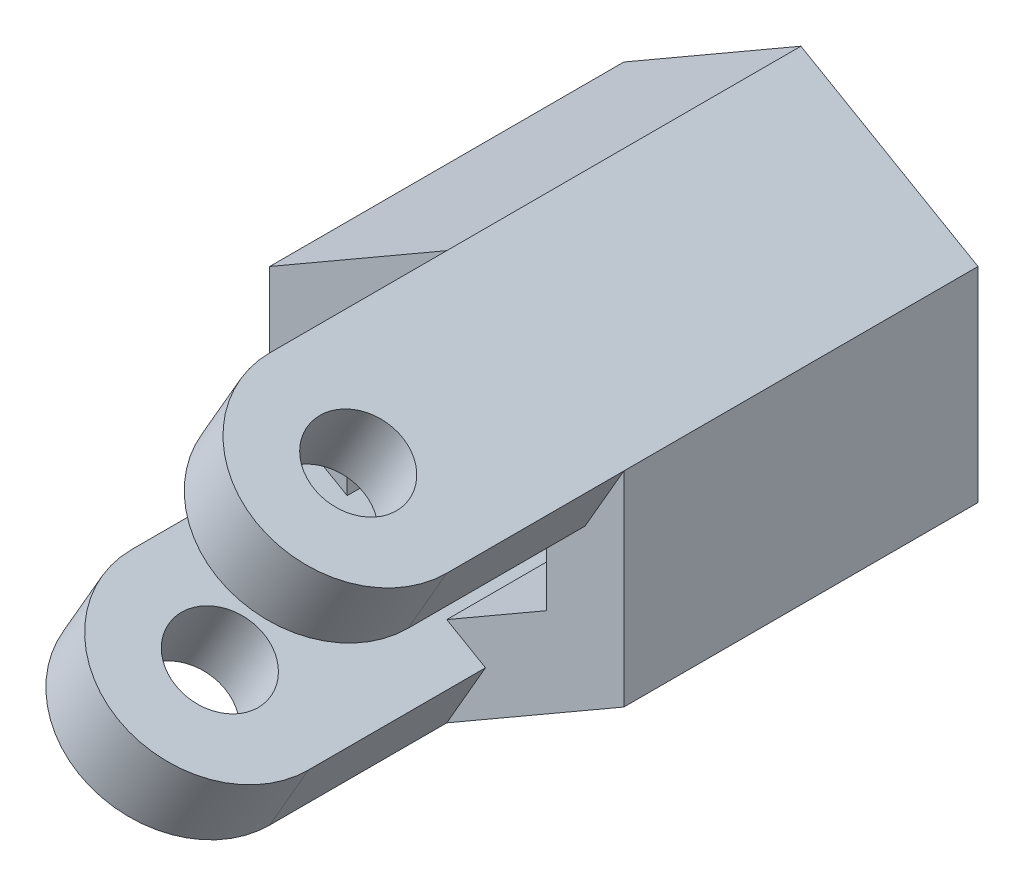
from build123d import *

# Parameters (mm, degrees)
EXTRUDE_1_DEPTH = 6
SKETCH_2_R      = 1.25
EXTRUDE_2_DEPTH = 2
SKETCH_3_R      = 1
EXTRUDE_4_DEPTH = 1.75
SKETCH_4_R      = 1
EXTRUDE_7_DEPTH = 1.75


with BuildPart() as part:
    # 스케치1 → 보스-돌출1 (new body)
    with BuildSketch(Plane.XY):
        Polygon((0, 4.618802154), (-4, 2.309401077), (-4, -2.309401077), (0, -4.618802154), (4, -2.309401077), (4, 2.309401077), align=None)
        Polygon((0, 2.598076211), (-2.25, 1.299038106), (-2.25, -1.299038106), (0, -2.598076211), (2.25, -1.299038106), (2.25, 1.299038106), align=None, mode=Mode.SUBTRACT)
    extrude(amount=EXTRUDE_1_DEPTH)

    # 스케치2 → 보스-돌출2 (add)
    with BuildSketch(Plane(origin=(0, 0, 0), x_dir=(-1, 0, 0), z_dir=(0, 0, -1))):
        Polygon((0, 4.618802154), (-4, 2.309401077), (-4, -2.309401077), (0, -4.618802154), (4, -2.309401077), (4, 2.309401077), align=None)
        Circle(SKETCH_2_R, mode=Mode.SUBTRACT)
    extrude(amount=EXTRUDE_2_DEPTH)

    # 스케치3 → 보스-돌출4 (add)
    with BuildSketch(Plane(origin=(2, 3.464101615, 0), x_dir=(0.866025404, -0.5, 0), z_dir=(0.5, 0.866025404, 0))):
        with BuildLine():
            Line((-2.309401077, -6), (2.309401077, -6))
            Line((2.309401077, -6), (2.309401077, -10))
            ThreePointArc((2.309401077, -10), (0, -12.309401077), (-2.309401077, -10))
            Line((-2.309401077, -10), (-2.309401077, -6))
        make_face()
        with Locations((0, -10)):
            Circle(SKETCH_3_R, mode=Mode.SUBTRACT)
    extrude(amount=-EXTRUDE_4_DEPTH)

    # 스케치4 → 보스-돌출7 (add)
    with BuildSketch(Plane(origin=(-2, -3.464101615, 0), x_dir=(0.866025404, -0.5, 0), z_dir=(-0.5, -0.866025404, 0))):
        with BuildLine():
            Line((-2.309401077, 10), (-2.309401077, 6))
            Line((-2.309401077, 6), (2.309401077, 6))
            Line((2.309401077, 6), (2.309401077, 10))
            ThreePointArc((2.309401077, 10), (0, 12.309401077), (-2.309401077, 10))
        make_face()
        with Locations((0, 10)):
            Circle(SKETCH_4_R, mode=Mode.SUBTRACT)
    extrude(amount=-EXTRUDE_7_DEPTH)


solid = part.part
